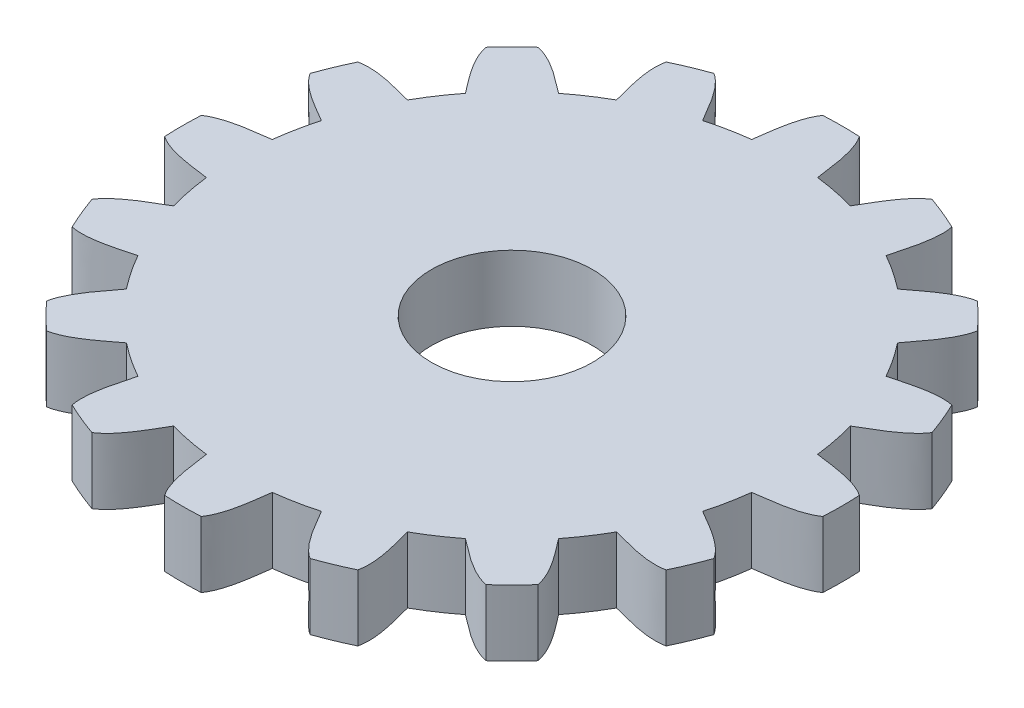
from build123d import *

# Parameters (mm, degrees)
SKETCH1_R           = 1.5
BOSS_EXTRUDE1_DEPTH = 0.36
BOSS_EXTRUDE2_DEPTH = 0.36
CIRPATTERN1_COUNT   = 16
SKETCH3_R           = 0.44
CUT_EXTRUDE1_DEPTH  = 1.3600001


with BuildPart() as part:
    # Sketch1 → Boss-Extrude1 (new body)
    with BuildSketch(Plane(origin=(0, 0, 0), x_dir=(1, 0, 0), z_dir=(0, 1, 0))):
        Circle(SKETCH1_R)
    extrude(amount=BOSS_EXTRUDE1_DEPTH)

    # Sketch2 → Boss-Extrude2 (add)
    with BuildSketch(Plane(origin=(0, 0, 0), x_dir=(1, 0, 0), z_dir=(0, 1, 0))):
        with BuildLine():
            ThreePointArc((-0.18, -1.489160838), (0, -1.5), (0.18, -1.489160838))
            add(Edge.make_bspline(
                [(0.18, -1.489160838), (0.165537061, -1.591536545), (0.153710341, -1.719311353), (0.1, -1.797220076)],
                knots=[0, 0, 0, 0, 1, 1, 1, 1], degree=3))
            ThreePointArc((0.1, -1.797220076), (0, -1.8), (-0.1, -1.797220076))
            add(Edge.make_bspline(
                [(-0.18, -1.489160838), (-0.165537061, -1.591536545), (-0.153710341, -1.719311353), (-0.1, -1.797220076)],
                knots=[0, 0, 0, 0, 1, 1, 1, 1], degree=3))
        make_face()
    boss_extrude2 = extrude(amount=BOSS_EXTRUDE2_DEPTH)

    # CirPattern1: Boss-Extrude2 ×16 about axis
    cirpattern1_axis = Axis((0, 0.36, 0), (0, -1, 0))
    for i in range(1, CIRPATTERN1_COUNT):
        add(boss_extrude2.rotate(cirpattern1_axis, i * 360 / CIRPATTERN1_COUNT))

    # Sketch3 → Cut-Extrude1 (cut, through all)
    with BuildSketch(Plane(origin=(0, 0.36, 0), x_dir=(1, 0, 0), z_dir=(0, 1, 0))):
        Circle(SKETCH3_R)
    extrude(amount=-CUT_EXTRUDE1_DEPTH, mode=Mode.SUBTRACT)


solid = part.part
